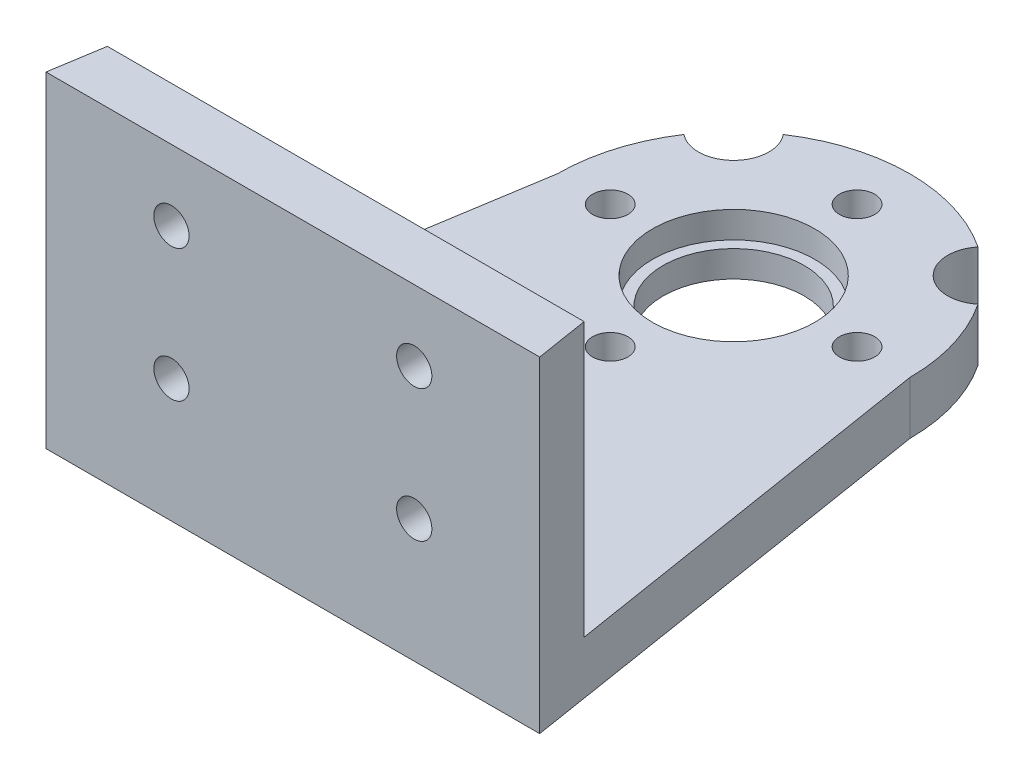
from build123d import *

# Parameters (mm, degrees)
BOSS_EXTRUDE1_DEPTH = 3
SKETCH2_R           = 4
CUT_EXTRUDE1_DEPTH  = 13
SKETCH3_R           = 1
CUT_EXTRUDE2_DEPTH  = 13
SKETCH4_R           = 1
CUT_EXTRUDE3_DEPTH  = 3
BOSS_EXTRUDE2_DEPTH = 15.5
SKETCH6_R           = 4.6
CUT_EXTRUDE4_DEPTH  = 1.5
SKETCH7_R           = 2
CUT_EXTRUDE5_DEPTH  = 10
SKETCH8_R           = 1
CUT_EXTRUDE6_DEPTH  = 10


with BuildPart() as part:
    # Sketch1 → Boss-Extrude1 (new body)
    with BuildSketch(Plane(origin=(0, 0, 0), x_dir=(1, 0, 0), z_dir=(0, 1, 0))):
        with BuildLine():
            Line((-10, 0), (-14, -25))
            Line((-14, -25), (14, -25))
            Line((14, -25), (10, 0))
            ThreePointArc((10, 0), (0, 10), (-10, 0))
        make_face()
    extrude(amount=BOSS_EXTRUDE1_DEPTH)

    # Sketch2 → Cut-Extrude1 (cut)
    with BuildSketch(Plane(origin=(0, 3, 0), x_dir=(1, 0, 0), z_dir=(0, 1, 0))):
        Circle(SKETCH2_R)
    extrude(amount=-CUT_EXTRUDE1_DEPTH, mode=Mode.SUBTRACT)

    # Sketch3 → Cut-Extrude2 (cut)
    with BuildSketch(Plane(origin=(0, 3, 0), x_dir=(1, 0, 0), z_dir=(0, 1, 0))):
        with Locations((-6.52, -19)):
            Circle(SKETCH3_R)
        with Locations((6.52, -19)):
            Circle(SKETCH3_R)
        with Locations((0, -19)):
            Circle(SKETCH3_R)
    extrude(amount=-CUT_EXTRUDE2_DEPTH, mode=Mode.SUBTRACT)

    # Sketch4 → Cut-Extrude3 (cut)
    with BuildSketch(Plane(origin=(0, 3, 0), x_dir=(1, 0, 0), z_dir=(0, 1, 0))):
        with Locations((0, -7)):
            Circle(SKETCH4_R)
        with Locations((-7, 0)):
            Circle(SKETCH4_R)
        with Locations((0, 7)):
            Circle(SKETCH4_R)
        with Locations((7, 0)):
            Circle(SKETCH4_R)
    extrude(amount=-CUT_EXTRUDE3_DEPTH, mode=Mode.SUBTRACT)

    # Sketch5 → Boss-Extrude2 (add)
    with BuildSketch(Plane(origin=(0, 3, 0), x_dir=(1, 0, 0), z_dir=(0, 1, 0))):
        Polygon((-13.52, -22), (13.52, -22), (14, -25), (-14, -25), align=None)
    extrude(amount=BOSS_EXTRUDE2_DEPTH)

    # Sketch6 → Cut-Extrude4 (cut)
    with BuildSketch(Plane(origin=(0, 3, 0), x_dir=(1, 0, 0), z_dir=(0, 1, 0))):
        Circle(SKETCH6_R)
    extrude(amount=-CUT_EXTRUDE4_DEPTH, mode=Mode.SUBTRACT)

    # Sketch7 → Cut-Extrude5 (cut)
    with BuildSketch(Plane(origin=(0, 3, 0), x_dir=(1, 0, 0), z_dir=(0, 1, 0))):
        with Locations((-7.071067812, 7.071067812)):
            Circle(SKETCH7_R)
        with Locations((7.071067812, 7.071067812)):
            Circle(SKETCH7_R)
    extrude(amount=-CUT_EXTRUDE5_DEPTH, mode=Mode.SUBTRACT)

    # Sketch8 → Cut-Extrude6 (cut)
    with BuildSketch(Plane(origin=(0, 0, 22), x_dir=(-1, 0, 0), z_dir=(0, 0, -1))):
        with Locations((6.885, 7)):
            Circle(SKETCH8_R)
        with Locations((-6.885, 7)):
            Circle(SKETCH8_R)
        with Locations((6.885, 14.5)):
            Circle(SKETCH8_R)
        with Locations((-6.885, 14.5)):
            Circle(SKETCH8_R)
    extrude(amount=-CUT_EXTRUDE6_DEPTH, mode=Mode.SUBTRACT)


solid = part.part
